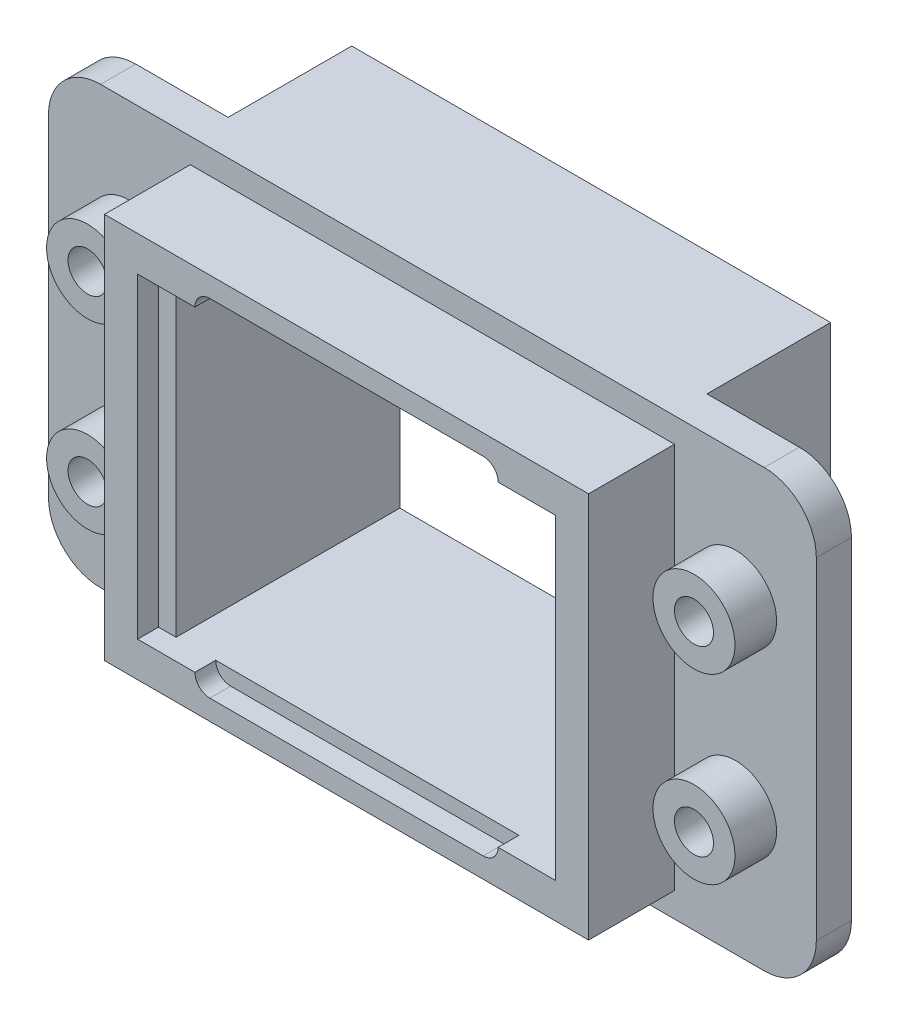
from build123d import *

# Parameters (mm, degrees)
EXTRUDE_1_DEPTH     = 1.35
SKETCH_8_W          = 18.4
SKETCH_8_H          = 16.75
EXTRUDE_4_DEPTH     = 4.75
SKETCH_2_R          = 1.575
EXTRUDE_2_DEPTH     = 1.6
SKETCH_4_W          = 18.6
SKETCH_4_H          = 14.85
EXTRUDE_3_DEPTH     = 3.3
SKETCH_3_W          = 14.7
SKETCH_3_H          = 12.15
CUT_EXTRUDE_1_DEPTH = 10.4
SKETCH_5_W          = 0.675
SKETCH_5_H          = 12.15
CUT_EXTRUDE_2_DEPTH = 0.8
SKETCH_6_R          = 0.75
CUT_EXTRUDE_3_DEPTH = 8.7


with BuildPart() as part:
    # Эскиз1 → Бобышка-Вытянуть1 (new body)
    with BuildSketch(Plane.XY):
        with BuildLine():
            Line((-12.75, -8.375), (12.75, -8.375))
            ThreePointArc((12.75, -8.375), (14.164213562, -7.789213562), (14.75, -6.375))
            Line((14.75, -6.375), (14.75, 6.375))
            ThreePointArc((14.75, 6.375), (14.164213562, 7.789213562), (12.75, 8.375))
            Line((12.75, 8.375), (-12.75, 8.375))
            ThreePointArc((-12.75, 8.375), (-14.164213562, 7.789213562), (-14.75, 6.375))
            Line((-14.75, 6.375), (-14.75, -6.375))
            ThreePointArc((-14.75, -6.375), (-14.164213562, -7.789213562), (-12.75, -8.375))
        make_face()
    extrude(amount=EXTRUDE_1_DEPTH)

    # Эскиз8 → Бобышка-Вытянуть4 (add)
    with BuildSketch(Plane(origin=(0, 0, 0), x_dir=(-1, 0, 0), z_dir=(0, 0, -1))):
        Rectangle(SKETCH_8_W, SKETCH_8_H)
    extrude(amount=EXTRUDE_4_DEPTH)

    # Эскиз2 → Бобышка-Вытянуть2 (add)
    with BuildSketch(Plane.XY.offset(1.35)):
        with Locations((-11.65, 3.5)):
            Circle(SKETCH_2_R)
        with Locations((11.65, 3.5)):
            Circle(SKETCH_2_R)
        with Locations((11.65, -3.5)):
            Circle(SKETCH_2_R)
        with Locations((-11.65, -3.5)):
            Circle(SKETCH_2_R)
    extrude(amount=EXTRUDE_2_DEPTH)

    # Эскиз4 → Бобышка-Вытянуть3 (add)
    with BuildSketch(Plane.XY.offset(1.35)):
        Rectangle(SKETCH_4_W, SKETCH_4_H)
    extrude(amount=EXTRUDE_3_DEPTH)

    # Эскиз3 → Вырез-Вытянуть1 (cut, through all)
    with BuildSketch(Plane.XY.offset(4.65)):
        Rectangle(SKETCH_3_W, SKETCH_3_H)
    extrude(amount=-CUT_EXTRUDE_1_DEPTH, mode=Mode.SUBTRACT)

    # Эскиз5 → Вырез-Вытянуть2 (cut)
    with BuildSketch(Plane.XY.offset(4.65)):
        with BuildLine():
            Line((-5.25, 6.65), (5.25, 6.65))
            ThreePointArc((5.25, 6.65), (5.825, 6.075), (5.25, 5.5))
            Line((5.25, 5.5), (-5.25, 5.5))
            ThreePointArc((-5.25, 5.5), (-5.825, 6.075), (-5.25, 6.65))
        make_face()
        with BuildLine():
            Line((-5.25, -6.65), (5.25, -6.65))
            ThreePointArc((5.25, -6.65), (5.825, -6.075), (5.25, -5.5))
            Line((5.25, -5.5), (-5.25, -5.5))
            ThreePointArc((-5.25, -5.5), (-5.825, -6.075), (-5.25, -6.65))
        make_face()
        with Locations((-7.6875, 0)):
            Rectangle(SKETCH_5_W, SKETCH_5_H)
        with Locations((7.6875, 0)):
            Rectangle(SKETCH_5_W, SKETCH_5_H)
    extrude(amount=-CUT_EXTRUDE_2_DEPTH, mode=Mode.SUBTRACT)

    # Эскиз6 → Вырез-Вытянуть3 (cut, through all)
    with BuildSketch(Plane.XY.offset(2.95)):
        with Locations((-11.65, 3.5)):
            Circle(SKETCH_6_R)
        with Locations((-11.65, -3.5)):
            Circle(SKETCH_6_R)
        with Locations((11.65, 3.5)):
            Circle(SKETCH_6_R)
        with Locations((11.65, -3.5)):
            Circle(SKETCH_6_R)
    extrude(amount=-CUT_EXTRUDE_3_DEPTH, mode=Mode.SUBTRACT)


solid = part.part
